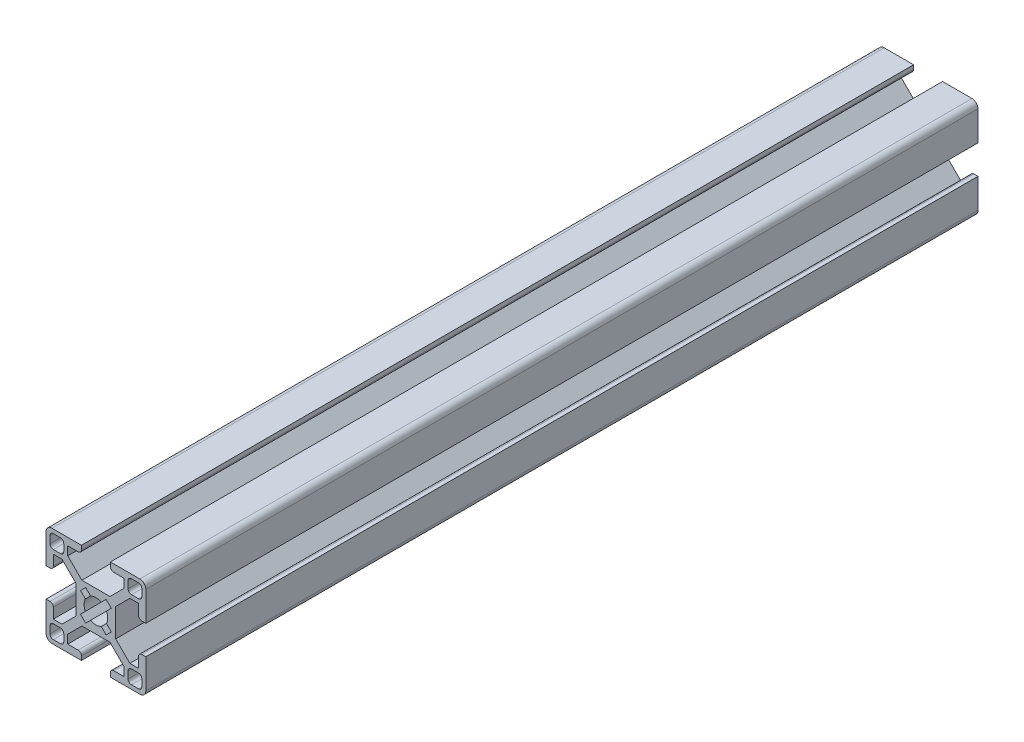
from build123d import *

# Parameters (mm, degrees)
SKETCH1_W           = 11.9
SKETCH1_H           = 5.95
BOSS_EXTRUDE1_DEPTH = 250
CUT_EXTRUDE1_DEPTH  = 251


with BuildPart() as part:
    # Sketch1 → Boss-Extrude1 (new body)
    with BuildSketch(Plane.XY):
        with BuildLine():
            Line((-4.350229073, 14.992640687), (-13.192640687, 14.992640687))
            ThreePointArc((-13.192640687, 14.992640687), (-14.465432893, 14.465432893), (-14.992640687, 13.192640687))
            Line((-14.992640687, 13.192640687), (-14.992640687, 4.350229073))
            Line((-14.992640687, 4.350229073), (-13.792640687, 4.350229073))
            ThreePointArc((-13.792640687, 4.350229073), (-13.085533906, 4.643122292), (-12.792640687, 5.350229073))
            Line((-12.792640687, 5.350229073), (-12.792640687, 8.460229073))
            Line((-12.792640687, 8.460229073), (-8.460229073, 8.460229073))
            Line((-8.460229073, 8.460229073), (-8.460229073, 12.792640687))
            Line((-8.460229073, 12.792640687), (-5.350229073, 12.792640687))
            ThreePointArc((-5.350229073, 12.792640687), (-4.643122292, 13.085533906), (-4.350229073, 13.792640687))
            Line((-4.350229073, 13.792640687), (-4.350229073, 14.992640687))
        make_face()
        with BuildLine():
            Line((-10.660229073, 13.792640687), (-12.792640687, 13.792640687))
            ThreePointArc((-12.792640687, 13.792640687), (-13.499747468, 13.499747468), (-13.792640687, 12.792640687))
            Line((-13.792640687, 12.792640687), (-13.792640687, 10.660229073))
            ThreePointArc((-13.792640687, 10.660229073), (-13.499747468, 9.953122292), (-12.792640687, 9.660229073))
            Line((-12.792640687, 9.660229073), (-10.660229073, 9.660229073))
            ThreePointArc((-10.660229073, 9.660229073), (-9.953122292, 9.953122292), (-9.660229073, 10.660229073))
            Line((-9.660229073, 10.660229073), (-9.660229073, 12.792640687))
            ThreePointArc((-9.660229073, 12.792640687), (-9.953122292, 13.499747468), (-10.660229073, 13.792640687))
        make_face(mode=Mode.SUBTRACT)
        Polygon((-5.95, 4.217588386), (-5.95, 5.95), (-4.217588386, 5.95), (-8.460229073, 10.192640687), (-8.460229073, 8.460229073), (-10.192640687, 8.460229073), align=None)
        with Locations((0, 2.975)):
            Rectangle(SKETCH1_W, SKETCH1_H)
        Polygon((8.460229073, 10.192640687), (4.217588386, 5.95), (5.95, 5.95), (5.95, 4.217588386), (10.192640687, 8.460229073), (8.460229073, 8.460229073), align=None)
        with BuildLine():
            Line((12.792640687, 8.460229073), (12.792640687, 5.350229073))
            ThreePointArc((12.792640687, 5.350229073), (13.085533906, 4.643122292), (13.792640687, 4.350229073))
            Line((13.792640687, 4.350229073), (14.992640687, 4.350229073))
            Line((14.992640687, 4.350229073), (14.992640687, 13.192640687))
            ThreePointArc((14.992640687, 13.192640687), (14.465432893, 14.465432893), (13.192640687, 14.992640687))
            Line((13.192640687, 14.992640687), (4.350229073, 14.992640687))
            Line((4.350229073, 14.992640687), (4.350229073, 13.792640687))
            ThreePointArc((4.350229073, 13.792640687), (4.643122292, 13.085533906), (5.350229073, 12.792640687))
            Line((5.350229073, 12.792640687), (8.460229073, 12.792640687))
            Line((8.460229073, 12.792640687), (8.460229073, 8.460229073))
            Line((8.460229073, 8.460229073), (12.792640687, 8.460229073))
        make_face()
        with BuildLine():
            ThreePointArc((9.660229073, 10.660229073), (9.953122292, 9.953122292), (10.660229073, 9.660229073))
            Line((10.660229073, 9.660229073), (12.792640687, 9.660229073))
            ThreePointArc((12.792640687, 9.660229073), (13.499747468, 9.953122292), (13.792640687, 10.660229073))
            Line((13.792640687, 10.660229073), (13.792640687, 12.792640687))
            ThreePointArc((13.792640687, 12.792640687), (13.499747468, 13.499747468), (12.792640687, 13.792640687))
            Line((12.792640687, 13.792640687), (10.660229073, 13.792640687))
            ThreePointArc((10.660229073, 13.792640687), (9.953122292, 13.499747468), (9.660229073, 12.792640687))
            Line((9.660229073, 12.792640687), (9.660229073, 10.660229073))
        make_face(mode=Mode.SUBTRACT)
    extrude(amount=-BOSS_EXTRUDE1_DEPTH)

    # Mirror1: part across plane


with BuildPart() as part_1:
    add(part.part)
    add(part.part.mirror(Plane(origin=(0, 0, -250), x_dir=(0, 0, 1), z_dir=(0, -1, 0))))

    # Sketch2 → Cut-Extrude1 (cut, through all)
    with BuildSketch(Plane.XY):
        with BuildLine():
            Line((-4.631549417, 3.075914498), (-3.16821753, 1.612582612))
            ThreePointArc((-3.16821753, 1.612582612), (-2.513764607, 2.513764607), (-1.612582612, 3.16821753))
            Line((-1.612582612, 3.16821753), (-3.075914498, 4.631549417))
            Line((-3.075914498, 4.631549417), (-4.631549417, 3.075914498))
        make_face()
        with BuildLine():
            Line((-3.16821753, 1.612582612), (-1.555634919, 0))
            Line((-1.555634919, 0), (0, 1.555634919))
            Line((0, 1.555634919), (-1.612582612, 3.16821753))
            ThreePointArc((-1.612582612, 3.16821753), (-2.513764607, 2.513764607), (-3.16821753, 1.612582612))
        make_face()
        with BuildLine():
            ThreePointArc((-3.16821753, 1.612582612), (-3.555, 0), (-3.16821753, -1.612582612))
            Line((-3.16821753, -1.612582612), (-1.555634919, 0))
            Line((-1.555634919, 0), (-3.16821753, 1.612582612))
        make_face()
        with BuildLine():
            Line((-4.631549417, -3.075914498), (-3.075914498, -4.631549417))
            Line((-3.075914498, -4.631549417), (-1.612582612, -3.16821753))
            ThreePointArc((-1.612582612, -3.16821753), (-2.513764607, -2.513764607), (-3.16821753, -1.612582612))
            Line((-3.16821753, -1.612582612), (-4.631549417, -3.075914498))
        make_face()
        with BuildLine():
            ThreePointArc((-3.16821753, -1.612582612), (-2.513764607, -2.513764607), (-1.612582612, -3.16821753))
            Line((-1.612582612, -3.16821753), (0, -1.555634919))
            Line((0, -1.555634919), (-1.555634919, 0))
            Line((-1.555634919, 0), (-3.16821753, -1.612582612))
        make_face()
        with BuildLine():
            Line((0, -1.555634919), (-1.612582612, -3.16821753))
            ThreePointArc((-1.612582612, -3.16821753), (0, -3.555), (1.612582612, -3.16821753))
            Line((1.612582612, -3.16821753), (0, -1.555634919))
        make_face()
        with BuildLine():
            Line((1.555634919, 0), (0, -1.555634919))
            Line((0, -1.555634919), (1.612582612, -3.16821753))
            ThreePointArc((1.612582612, -3.16821753), (2.513764607, -2.513764607), (3.16821753, -1.612582612))
            Line((3.16821753, -1.612582612), (1.555634919, 0))
        make_face()
        with BuildLine():
            Line((3.16821753, 1.612582612), (1.555634919, 0))
            Line((1.555634919, 0), (3.16821753, -1.612582612))
            ThreePointArc((3.16821753, -1.612582612), (3.456952294, -0.829159719), (3.555, 0))
            ThreePointArc((3.555, 0), (3.456952294, 0.829159719), (3.16821753, 1.612582612))
        make_face()
        Polygon((-1.555634919, 0), (0, -1.555634919), (1.555634919, 0), (0, 1.555634919), align=None)
        with BuildLine():
            Line((0, 1.555634919), (1.555634919, 0))
            Line((1.555634919, 0), (3.16821753, 1.612582612))
            ThreePointArc((3.16821753, 1.612582612), (2.513764607, 2.513764607), (1.612582612, 3.16821753))
            Line((1.612582612, 3.16821753), (0, 1.555634919))
        make_face()
        with BuildLine():
            Line((-1.612582612, 3.16821753), (0, 1.555634919))
            Line((0, 1.555634919), (1.612582612, 3.16821753))
            ThreePointArc((1.612582612, 3.16821753), (0, 3.555), (-1.612582612, 3.16821753))
        make_face()
        with BuildLine():
            ThreePointArc((1.612582612, 3.16821753), (2.513764607, 2.513764607), (3.16821753, 1.612582612))
            Line((3.16821753, 1.612582612), (4.631549417, 3.075914498))
            Line((4.631549417, 3.075914498), (3.075914498, 4.631549417))
            Line((3.075914498, 4.631549417), (1.612582612, 3.16821753))
        make_face()
        with BuildLine():
            ThreePointArc((3.16821753, -1.612582612), (2.513764607, -2.513764607), (1.612582612, -3.16821753))
            Line((1.612582612, -3.16821753), (3.075914498, -4.631549417))
            Line((3.075914498, -4.631549417), (4.631549417, -3.075914498))
            Line((4.631549417, -3.075914498), (3.16821753, -1.612582612))
        make_face()
    extrude(amount=-CUT_EXTRUDE1_DEPTH, mode=Mode.SUBTRACT)


solid = part_1.part
